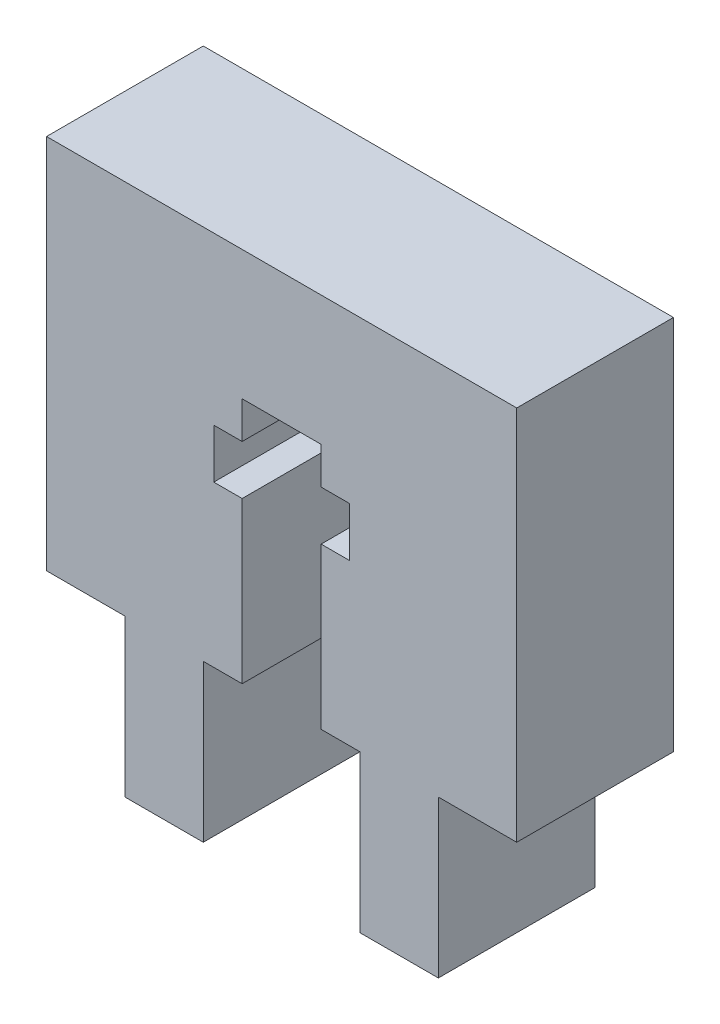
from build123d import *

# Parameters (mm, degrees)
BOSS_EXTRUDE1_DEPTH = 6.35
CUT_EXTRUDE3_DEPTH  = 7.35


with BuildPart() as part:
    # Sketch1 → Boss-Extrude1 (new body)
    with BuildSketch(Plane.XY):
        Polygon((-3.175, 15.24), (15.875, 15.24), (15.875, 0), (12.7, 0), (12.7, -6.35), (9.525, -6.35), (9.525, 0), (3.175, 0), (3.175, -6.35), (0, -6.35), (0, 0), (-3.175, 0), align=None)
    extrude(amount=BOSS_EXTRUDE1_DEPTH)

    # Sketch3 → Cut-Extrude3 (cut, through all)
    with BuildSketch(Plane.XY.offset(6.35)):
        Polygon((4.75, 0), (7.95, 0), (7.95, 6.5), (9.1, 6.5), (9.1, 8.5), (7.95, 8.5), (7.95, 10), (4.75, 10), (4.75, 8.5), (3.6, 8.5), (3.6, 6.5), (4.75, 6.5), align=None)
    extrude(amount=-CUT_EXTRUDE3_DEPTH, mode=Mode.SUBTRACT)


solid = part.part
